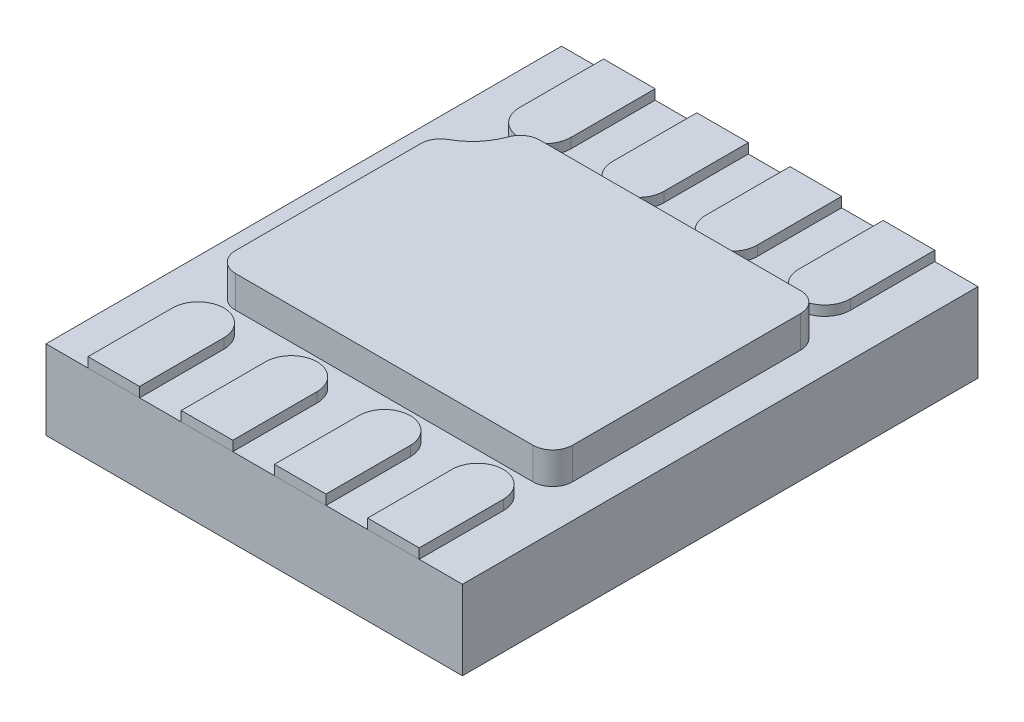
from build123d import *

# Parameters (mm, degrees)
SKETCH1_W           = 2.1
SKETCH1_H           = 2.6
BOSS_EXTRUDE1_DEPTH = 0.4
BOSS_EXTRUDE2_DEPTH = 0.16
BOSS_EXTRUDE3_DEPTH = 0.05


with BuildPart() as part:
    # Sketch1 → Boss-Extrude1 (new body)
    with BuildSketch(Plane(origin=(0, 0, 0), x_dir=(1, 0, 0), z_dir=(0, 1, 0))):
        Rectangle(SKETCH1_W, SKETCH1_H)
    extrude(amount=BOSS_EXTRUDE1_DEPTH)

    # Sketch2 → Boss-Extrude2 (add)
    with BuildSketch(Plane(origin=(0, 0.4, 0), x_dir=(1, 0, 0), z_dir=(0, 1, 0))):
        with BuildLine():
            Line((-0.819602151, 0.359414715), (-0.819602151, -0.575))
            ThreePointArc((-0.819602151, -0.575), (-0.79031283, -0.645710678), (-0.719602151, -0.675))
            Line((-0.719602151, -0.675), (0.780397849, -0.675))
            ThreePointArc((0.780397849, -0.675), (0.851108527, -0.645710678), (0.880397849, -0.575))
            Line((0.880397849, -0.575), (0.880397849, 0.575))
            ThreePointArc((0.880397849, 0.575), (0.851108527, 0.645710678), (0.780397849, 0.675))
            Line((0.780397849, 0.675), (-0.53439143, 0.675))
            ThreePointArc((-0.53439143, 0.675), (-0.591852021, 0.656843023), (-0.6284464, 0.608965609))
            ThreePointArc((-0.6284464, 0.608965609), (-0.683055267, 0.515367559), (-0.767354441, 0.447276646))
            ThreePointArc((-0.767354441, 0.447276646), (-0.805553385, 0.410526216), (-0.819602151, 0.359414715))
        make_face()
    extrude(amount=BOSS_EXTRUDE2_DEPTH)


with BuildPart() as body_2:
    # Sketch3 → Boss-Extrude3 (new body)
    with BuildSketch(Plane(origin=(0, 0.4, 0), x_dir=(1, 0, 0), z_dir=(0, 1, 0))):
        with BuildLine():
            Line((-0.368, -0.875), (-0.368, -1.3))
            Line((-0.368, -1.3), (-0.108, -1.3))
            Line((-0.108, -1.3), (-0.108, -0.875))
            ThreePointArc((-0.108, -0.875), (-0.238, -1.005), (-0.368, -0.875))
        make_face()
        with BuildLine():
            ThreePointArc((-0.108, -0.875), (-0.238, -0.745), (-0.368, -0.875))
            Line((-0.368, -0.875), (-0.108, -0.875))
        make_face()
        with BuildLine():
            Line((-0.108, -0.875), (-0.368, -0.875))
            ThreePointArc((-0.368, -0.875), (-0.238, -1.005), (-0.108, -0.875))
        make_face()
        with BuildLine():
            ThreePointArc((-0.578, -0.875), (-0.708, -0.745), (-0.838, -0.875))
            Line((-0.838, -0.875), (-0.578, -0.875))
        make_face()
        with BuildLine():
            Line((-0.578, -0.875), (-0.838, -0.875))
            ThreePointArc((-0.838, -0.875), (-0.708, -1.005), (-0.578, -0.875))
        make_face()
        with BuildLine():
            Line((-0.838, -0.875), (-0.838, -1.3))
            Line((-0.838, -1.3), (-0.578, -1.3))
            Line((-0.578, -1.3), (-0.578, -0.875))
            ThreePointArc((-0.578, -0.875), (-0.708, -1.005), (-0.838, -0.875))
        make_face()
        with BuildLine():
            Line((0.102, -0.875), (0.102, -1.3))
            Line((0.102, -1.3), (0.362, -1.3))
            Line((0.362, -1.3), (0.362, -0.875))
            ThreePointArc((0.362, -0.875), (0.232, -1.005), (0.102, -0.875))
        make_face()
        with BuildLine():
            ThreePointArc((0.362, -0.875), (0.232, -0.745), (0.102, -0.875))
            Line((0.102, -0.875), (0.362, -0.875))
        make_face()
        with BuildLine():
            Line((0.362, -0.875), (0.102, -0.875))
            ThreePointArc((0.102, -0.875), (0.232, -1.005), (0.362, -0.875))
        make_face()
        with BuildLine():
            Line((0.572, -0.875), (0.572, -1.3))
            Line((0.572, -1.3), (0.832, -1.3))
            Line((0.832, -1.3), (0.832, -0.875))
            ThreePointArc((0.832, -0.875), (0.702, -1.005), (0.572, -0.875))
        make_face()
        with BuildLine():
            ThreePointArc((0.832, -0.875), (0.702, -0.745), (0.572, -0.875))
            Line((0.572, -0.875), (0.832, -0.875))
        make_face()
        with BuildLine():
            Line((0.832, -0.875), (0.572, -0.875))
            ThreePointArc((0.572, -0.875), (0.702, -1.005), (0.832, -0.875))
        make_face()
    boss_extrude3 = extrude(amount=BOSS_EXTRUDE3_DEPTH)


with BuildPart() as part_1:
    add(part.part)

    # Mirror1: Boss-Extrude3 across plane
    add(boss_extrude3.mirror(Plane(origin=(0, 0, 0), x_dir=(1, 0, 0), z_dir=(0, 0, -1))))


solid = Compound([body_2.part, part_1.part])
